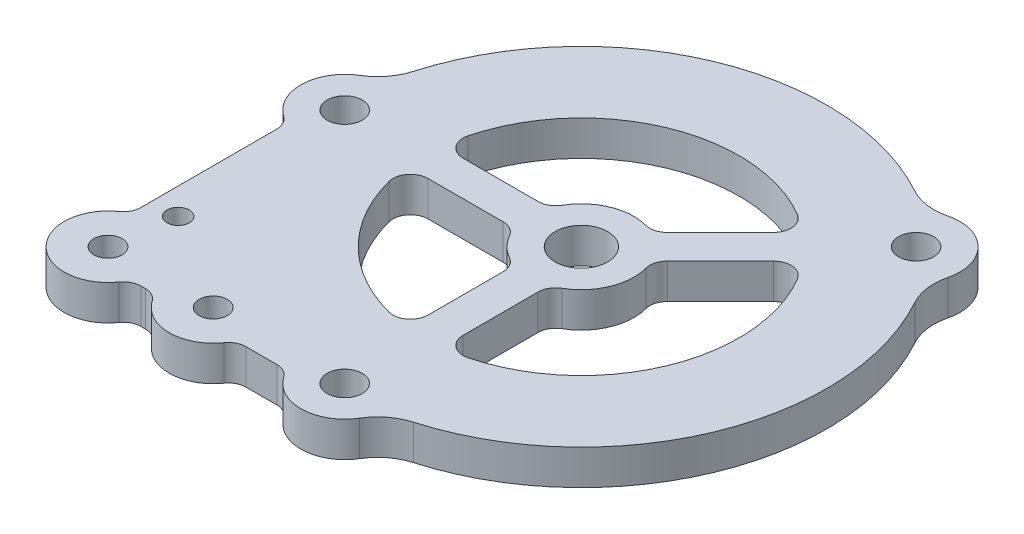
from build123d import *

# Parameters (mm, degrees)
BOSS_EXTRUDE1_DEPTH         = 6.35
SKETCH2_R                   = 4.7625
CUT_EXTRUDE1_DEPTH          = 7.35
F_1_4_0_25_DIAMETER_HOLE1_D = 6.35
CUT_EXTRUDE2_DEPTH          = 7.35
FILLET1_R                   = 3.175
BOSS_EXTRUDE2_DEPTH         = 6.35
F_10_CLEARANCE_HOLE1_D      = 5.1054
CUT_EXTRUDE5_DEPTH          = 6.35
FILLET3_R                   = 3.175
F_10_32_TAPPED_HOLE1_D      = 4.0386


with BuildPart() as part:
    # Sketch1 → Boss-Extrude1 (new body)
    with BuildSketch(Plane(origin=(0, 0, 0), x_dir=(1, 0, 0), z_dir=(0, 1, 0))):
        with BuildLine():
            ThreePointArc((-42.706862745, -12.325841735), (-31.430896424, -31.430896424), (-12.325841735, -42.706862745))
            ThreePointArc((-12.325841735, -42.706862745), (-9.162618669, -44.306267621), (-6.803224334, -46.951515152))
            ThreePointArc((-6.803224334, -46.951515152), (0, -50.8), (6.803224334, -46.951515152))
            ThreePointArc((6.803224334, -46.951515152), (9.162618669, -44.306267621), (12.325841735, -42.706862745))
            ThreePointArc((12.325841735, -42.706862745), (41.06644522, -17.010278569), (38.913998525, 21.482625976))
            ThreePointArc((38.913998525, 21.482625976), (37.808212078, 24.85031249), (38.010340811, 28.38912869))
            ThreePointArc((38.010340811, 28.38912869), (35.921024484, 35.921024484), (28.38912869, 38.010340811))
            ThreePointArc((28.38912869, 38.010340811), (24.85031249, 37.808212078), (21.482625976, 38.913998525))
            ThreePointArc((21.482625976, 38.913998525), (-17.010278569, 41.06644522), (-42.706862745, 12.325841735))
            ThreePointArc((-42.706862745, 12.325841735), (-44.306267621, 9.162618669), (-46.951515152, 6.803224334))
            ThreePointArc((-46.951515152, 6.803224334), (-50.8, 0), (-46.951515152, -6.803224334))
            ThreePointArc((-46.951515152, -6.803224334), (-44.306267621, -9.162618669), (-42.706862745, -12.325841735))
        make_face()
    extrude(amount=BOSS_EXTRUDE1_DEPTH)

    # Sketch2 → Cut-Extrude1 (cut, through all)
    with BuildSketch(Plane(origin=(0, 6.35, 0), x_dir=(1, 0, 0), z_dir=(0, 1, 0))):
        Circle(SKETCH2_R)
    extrude(amount=-CUT_EXTRUDE1_DEPTH, mode=Mode.SUBTRACT)

    # 1/4 (0.25) Diameter Hole1 (through all)
    with Locations(Plane(origin=(0, 6.35, 0), x_dir=(1, 0, 0), z_dir=(0, 1, 0))):
        with Locations((-42.8625, 0), (30.308364409, 30.308364409), (0, -42.8625)):
            Hole(F_1_4_0_25_DIAMETER_HOLE1_D / 2)

    # Sketch5 → Cut-Extrude2 (cut, through all)
    with BuildSketch(Plane(origin=(0, 6.35, 0), x_dir=(1, 0, 0), z_dir=(0, 1, 0))):
        with BuildLine():
            Line((-28.398063314, 3.175), (-8.980256121, 3.175))
            ThreePointArc((-8.980256121, 3.175), (-3.645059693, 8.799952547), (4.10493597, 8.59506403))
            Line((4.10493597, 8.59506403), (17.835399112, 22.325527172))
            ThreePointArc((17.835399112, 22.325527172), (-10.93517908, 26.399857642), (-28.398063314, 3.175))
        make_face()
        with BuildLine():
            Line((-28.398063314, -3.175), (-8.980256121, -3.175))
            ThreePointArc((-8.980256121, -3.175), (-6.735192091, -6.735192091), (-3.175, -8.980256121))
            Line((-3.175, -8.980256121), (-3.175, -28.398063314))
            ThreePointArc((-3.175, -28.398063314), (-20.205576272, -20.205576272), (-28.398063314, -3.175))
        make_face()
        with BuildLine():
            Line((22.325527172, 17.835399112), (8.59506403, 4.10493597))
            ThreePointArc((8.59506403, 4.10493597), (8.799952547, -3.645059693), (3.175, -8.980256121))
            Line((3.175, -8.980256121), (3.175, -28.398063314))
            ThreePointArc((3.175, -28.398063314), (26.399857642, -10.93517908), (22.325527172, 17.835399112))
        make_face()
    extrude(amount=-CUT_EXTRUDE2_DEPTH, mode=Mode.SUBTRACT)

    # Fillet1
    fillet1_edges = [part.edges().sort_by_distance(p)[0] for p in [
        (22.325527172, 3.175, -17.835399112),
        (3.175, 3.175, 28.398063314),
        (3.175, 3.175, 8.980256121),
        (8.59506403, 3.175, -4.10493597),
        (-3.175, 3.175, 28.398063314),
        (-28.398063314, 3.175, 3.175),
        (-8.980256121, 3.175, 3.175),
        (-3.175, 3.175, 8.980256121),
        (-28.398063314, 3.175, -3.175),
        (17.835399112, 3.175, -22.325527172),
        (4.10493597, 3.175, -8.59506403),
        (-8.980256121, 3.175, -3.175),
    ]]
    fillet(fillet1_edges, radius=FILLET1_R)

    # Sketch8 → Boss-Extrude2 (add)
    with BuildSketch(Plane(origin=(0, 6.35, 0), x_dir=(1, 0, 0), z_dir=(0, 1, 0))):
        with BuildLine():
            Line((-50.8, 0), (-50.8, -42.8625))
            ThreePointArc((-50.8, -42.8625), (-48.475160076, -48.475160076), (-42.8625, -50.8))
            Line((-42.8625, -50.8), (0, -50.8))
            ThreePointArc((0, -50.8), (-3.908154839, -49.771206971), (-6.803224334, -46.951515152))
            ThreePointArc((-6.803224334, -46.951515152), (-9.162618669, -44.306267621), (-12.325841735, -42.706862745))
            ThreePointArc((-12.325841735, -42.706862745), (-31.430896424, -31.430896424), (-42.706862745, -12.325841735))
            ThreePointArc((-42.706862745, -12.325841735), (-44.306267621, -9.162618669), (-46.951515152, -6.803224334))
            ThreePointArc((-46.951515152, -6.803224334), (-49.771206971, -3.908154839), (-50.8, 0))
        make_face()
    extrude(amount=-BOSS_EXTRUDE2_DEPTH)

    # #10 Clearance Hole1 (through all)
    with Locations(Plane(origin=(0, 6.35, 0), x_dir=(1, 0, 0), z_dir=(0, 1, 0))):
        with Locations((-42.8625, -42.8625), (-23.8125, -42.8625)):
            Hole(F_10_CLEARANCE_HOLE1_D / 2)

    # Sketch15 → Cut-Extrude5 (cut)
    with BuildSketch(Plane(origin=(0, 6.35, 0), x_dir=(1, 0, 0), z_dir=(0, 1, 0))):
        with BuildLine():
            ThreePointArc((-46.0375, -35.587661084), (-49.503488961, -38.5149522), (-50.8, -42.8625))
            Line((-50.8, -42.8625), (-50.8, 0))
            ThreePointArc((-50.8, 0), (-49.503488961, -4.3475478), (-46.0375, -7.274838916))
            Line((-46.0375, -7.274838916), (-46.0375, -35.587661084))
        make_face()
        with BuildLine():
            Line((-31.087338916, -46.0375), (-35.587661084, -46.0375))
            ThreePointArc((-35.587661084, -46.0375), (-38.5149522, -49.503488961), (-42.8625, -50.8))
            Line((-42.8625, -50.8), (-23.8125, -50.8))
            ThreePointArc((-23.8125, -50.8), (-28.1600478, -49.503488961), (-31.087338916, -46.0375))
        make_face()
        with BuildLine():
            ThreePointArc((-16.537661084, -46.0375), (-19.4649522, -49.503488961), (-23.8125, -50.8))
            Line((-23.8125, -50.8), (0, -50.8))
            ThreePointArc((0, -50.8), (-4.3475478, -49.503488961), (-7.274838916, -46.0375))
            Line((-7.274838916, -46.0375), (-16.537661084, -46.0375))
        make_face()
    extrude(amount=-CUT_EXTRUDE5_DEPTH, mode=Mode.SUBTRACT)

    # Fillet3
    fillet3_edges = [part.edges().sort_by_distance(p)[0] for p in [
        (-46.0375, 3.175, 35.587661084),
        (-46.0375, 3.175, 7.274838916),
        (-35.587661084, 3.175, 46.0375),
        (-31.087338916, 3.175, 46.0375),
        (-16.537661084, 3.175, 46.0375),
        (-7.274838916, 3.175, 46.0375),
    ]]
    fillet(fillet3_edges, radius=FILLET3_R)

    # #10-32 Tapped Hole1 (through all)
    with Locations(Plane(origin=(0, 6.35, 0), x_dir=(1, 0, 0), z_dir=(0, 1, 0))):
        with Locations((-41.275, -31.75)):
            Hole(F_10_32_TAPPED_HOLE1_D / 2)


solid = part.part
